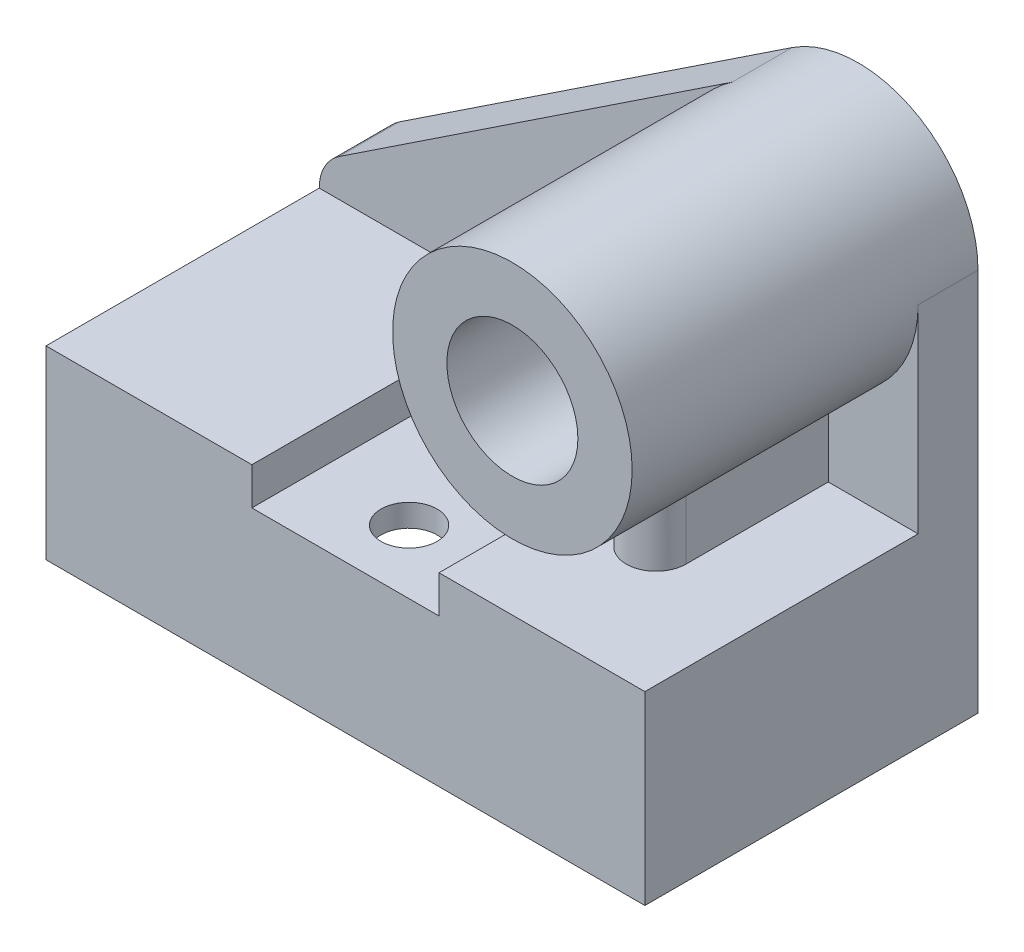
from build123d import *

# Parameters (mm, degrees)
SKETCH1_W           = 160
SKETCH1_H           = 49.5
BOSS_EXTRUDE1_DEPTH = 89
BOSS_EXTRUDE2_DEPTH = 16
SKETCH2_W           = 50
SKETCH2_H           = 54
SKETCH2_R           = 7.5
CUT_EXTRUDE1_DEPTH  = 10
SHELL2_T            = -6
SKETCH1_4_R         = 17.5
BOSS_EXTRUDE3_DEPTH = 92.4
BOSS_EXTRUDE4_REACH = 205.378
SKETCH2_8_R         = 7.5
CUT_EXTRUDE4_DEPTH  = 204.378366598


with BuildPart() as part:
    # Sketch1 → Boss-Extrude1 (new body)
    with BuildSketch(Plane.XY):
        with Locations((-80, 24.75)):
            Rectangle(SKETCH1_W, SKETCH1_H)
    extrude(amount=BOSS_EXTRUDE1_DEPTH)

    # Sketch2 → Cut-Extrude1 (cut)
    with BuildSketch(Plane(origin=(0, 49.5, 0), x_dir=(1, 0, 0), z_dir=(0, 1, 0))):
        with Locations((-80, -62)):
            Rectangle(SKETCH2_W, SKETCH2_H)
        with Locations((-80, -72)):
            Circle(SKETCH2_R, mode=Mode.SUBTRACT)
        with Locations((-80, -47)):
            Circle(SKETCH2_R, mode=Mode.SUBTRACT)
    extrude(amount=-CUT_EXTRUDE1_DEPTH, mode=Mode.SUBTRACT)

    # Shell2
    shell2_openings = [part.faces().sort_by_distance(p)[0] for p in [
        (-80, 0, 44.5),
    ]]
    offset(amount=SHELL2_T, openings=shell2_openings, kind=Kind.INTERSECTION)



with BuildPart() as body_2:
    # Sketch1_3 → Boss-Extrude2 (new body)
    with BuildSketch(Plane.XY):
        with BuildLine():
            Line((-160, 49.5), (0, 49.5))
            Line((0, 49.5), (0, 102.5))
            ThreePointArc((0, 102.5), (-47.127064471, 74.301207109), (-49.698245031, 129.160309879))
            Line((-49.698245031, 129.160309879), (-154.636841887, 59.497616205))
            ThreePointArc((-154.636841887, 59.497616205), (-158.574547334, 55.172649177), (-160, 49.5))
        make_face()
    extrude(amount=BOSS_EXTRUDE2_DEPTH)


with BuildPart() as body_3:
    # Sketch1_4 → Boss-Extrude3 (new body)
    with BuildSketch(Plane.XY):
        with BuildLine():
            ThreePointArc((-49.698245031, 129.160309879), (-47.127064471, 74.301207109), (0, 102.5))
            ThreePointArc((0, 102.5), (-16.872935529, 130.698792891), (-49.698245031, 129.160309879))
        make_face()
        with Locations((-32, 102.5)):
            Circle(SKETCH1_4_R, mode=Mode.SUBTRACT)
    extrude(amount=BOSS_EXTRUDE3_DEPTH)


with BuildPart() as part_1:
    add(part.part)

    # Sketch2_6 → Boss-Extrude4 (add, up to next)
    with BuildSketch(Plane(origin=(0, 49.5, 0), x_dir=(1, 0, 0), z_dir=(0, 1, 0)), mode=Mode.PRIVATE) as boss_extrude4_sk1:
        with BuildLine():
            Line((-24, -16), (-40, -16))
            Line((-40, -16), (-40, -54))
            ThreePointArc((-40, -54), (-32, -62), (-24, -54))
            Line((-24, -54), (-24, -16))
        make_face()
    boss_extrude4_tool1 = extrude(boss_extrude4_sk1.sketch, amount=BOSS_EXTRUDE4_REACH, mode=Mode.PRIVATE) - body_3.part
    add(boss_extrude4_tool1.solids().sort_by_distance((-32, 49.5, 38.177591))[0])

    # Sketch2_8 → Cut-Extrude4 (cut, through all)
    with BuildSketch(Plane(origin=(0, 49.5, 0), x_dir=(1, 0, 0), z_dir=(0, 1, 0))):
        with Locations((-80, -47)):
            Circle(SKETCH2_8_R)
        with Locations((-80, -72)):
            Circle(SKETCH2_8_R)
    extrude(amount=-CUT_EXTRUDE4_DEPTH, mode=Mode.SUBTRACT)


with BuildPart() as body_3_1:
    add(body_3.part)

    # Combine1: union part, body 2
    add(part_1.part)
    add(body_2.part)


solid = body_3_1.part
